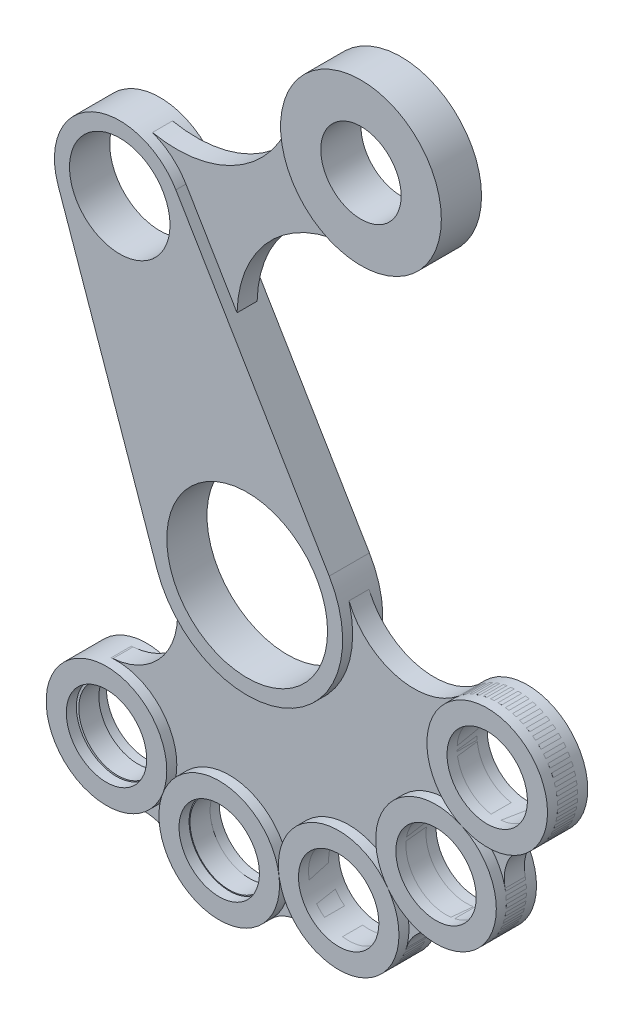
from build123d import *

# Parameters (mm, degrees)
SKETCH1_R             = 25
SKETCH1_R_2           = 40
BOSS_EXTRUDE1_DEPTH   = 10
SKETCH2_R             = 40
SKETCH2_R_2           = 20
BOSS_EXTRUDE2_DEPTH   = 10
SKETCH2_R_3           = 30
BOSS_EXTRUDE2_2_DEPTH = 10
BOSS_EXTRUDE2_3_DEPTH = 10
BOSS_EXTRUDE2_4_DEPTH = 10
BOSS_EXTRUDE2_5_DEPTH = 10
BOSS_EXTRUDE2_6_DEPTH = 10
SKETCH3_R             = 19.3844034
SKETCH3_R_2           = 19.543211722
SKETCH3_R_3           = 20
BOSS_EXTRUDE3_DEPTH   = 5


with BuildPart() as part:
    # Sketch1 → Boss-Extrude1 (new body, symmetric)
    with BuildSketch(Plane.XY):
        with BuildLine():
            Line((-94.071143909, 125.230046249), (-44.841671867, -15.667624713))
            ThreePointArc((-44.841671867, -15.667624713), (20.073190162, -43.050168835), (40.827095802, 24.277525582))
            Line((40.827095802, 24.277525582), (-35.455671293, 152.560938556))
            ThreePointArc((-35.455671293, 152.560938556), (-77.124288005, 165.405378677), (-94.071143909, 125.230046249))
        make_face()
        with Locations((-63.39, 135.95)):
            Circle(SKETCH1_R, mode=Mode.SUBTRACT)
        Circle(SKETCH1_R_2, mode=Mode.SUBTRACT)
    extrude(amount=BOSS_EXTRUDE1_DEPTH, both=True)



with BuildPart() as body_2:
    # Sketch2 → Boss-Extrude2 (new body, symmetric)
    with BuildSketch(Plane.XY):
        with Locations((56.61, 205.95)):
            Circle(SKETCH2_R)
        with Locations((56.61, 205.95)):
            Circle(SKETCH2_R_2, mode=Mode.SUBTRACT)
    extrude(amount=BOSS_EXTRUDE2_DEPTH, both=True)


with BuildPart() as body_3:
    # Sketch2 → Boss-Extrude2 2 (new body, symmetric)
    with BuildSketch(Plane.XY):
        with Locations((119.436136102, -23.248858997)):
            Circle(SKETCH2_R_3)
        with Locations((119.436136102, -23.248858997)):
            Circle(SKETCH2_R_2, mode=Mode.SUBTRACT)
    extrude(amount=BOSS_EXTRUDE2_2_DEPTH, both=True)


with BuildPart() as body_4:
    # Sketch2 → Boss-Extrude2 3 (new body, symmetric)
    with BuildSketch(Plane.XY):
        with Locations((93.96134696, -77.572289653)):
            Circle(SKETCH2_R_3)
        with Locations((93.96134696, -77.572289653)):
            Circle(SKETCH2_R_2, mode=Mode.SUBTRACT)
    extrude(amount=BOSS_EXTRUDE2_3_DEPTH, both=True)


with BuildPart() as body_5:
    # Sketch2 → Boss-Extrude2 4 (new body, symmetric)
    with BuildSketch(Plane.XY):
        with Locations((45.527914191, -112.987012442)):
            Circle(SKETCH2_R_3)
        with Locations((45.527914191, -112.987012442)):
            Circle(SKETCH2_R_2, mode=Mode.SUBTRACT)
    extrude(amount=BOSS_EXTRUDE2_4_DEPTH, both=True)


with BuildPart() as body_6:
    # Sketch2 → Boss-Extrude2 5 (new body, symmetric)
    with BuildSketch(Plane.XY):
        with Locations((-13.897344029, -121.27185918)):
            Circle(SKETCH2_R_3)
        with Locations((-13.897344029, -121.27185918)):
            Circle(SKETCH2_R_2, mode=Mode.SUBTRACT)
    extrude(amount=BOSS_EXTRUDE2_5_DEPTH, both=True)


with BuildPart() as body_7:
    # Sketch2 → Boss-Extrude2 6 (new body, symmetric)
    with BuildSketch(Plane.XY):
        with Locations((-70, -100)):
            Circle(SKETCH2_R_3)
        with Locations((-70, -100)):
            Circle(SKETCH2_R_2, mode=Mode.SUBTRACT)
    extrude(amount=BOSS_EXTRUDE2_6_DEPTH, both=True)


with BuildPart() as part_1:
    add(part.part)

    add(body_2.part)  # Boss-Extrude3 merges body 2
    # Sketch3 → Boss-Extrude3 (add, symmetric)
    with BuildSketch(Plane.XY):
        with BuildLine():
            Line((-35.455671293, 152.560938556), (-10.035224998, 109.811812714))
            ThreePointArc((-10.035224998, 109.811812714), (7.949605082, 150.52428347), (49.454864541, 166.595152312))
            ThreePointArc((49.454864541, 166.595152312), (25.900022644, 180.319992376), (16.61, 205.95))
            ThreePointArc((16.61, 205.95), (-10.311432558, 173.218996741), (-52.146467894, 166.443162935))
            ThreePointArc((-52.146467894, 166.443162935), (-42.607670177, 160.936891906), (-35.455671293, 152.560938556))
        make_face()
        with BuildLine():
            ThreePointArc((100.317104635, -0.130411044), (69.52759131, -7.115068147), (45.641469433, 13.530336844))
            ThreePointArc((45.641469433, 13.530336844), (17.950677407, -42.218066937), (-41.517383039, -23.827464064))
            ThreePointArc((-41.517383039, -23.827464064), (-45.355797063, -54.34871747), (-71.807905384, -70.051147126))
            ThreePointArc((-71.807905384, -70.051147126), (-98.898686089, -104.97930919), (-61.677946881, -128.822620142))
            ThreePointArc((-61.677946881, -128.822620142), (-49.039291741, -129.336814914), (-39.236884492, -137.331363814))
            ThreePointArc((-39.236884492, -137.331363814), (-17.248670052, -151.084081738), (7.244172132, -142.556508447))
            ThreePointArc((7.244172132, -142.556508447), (18.576900661, -136.937855218), (31.01427542, -139.242569752))
            ThreePointArc((31.01427542, -139.242569752), (56.793105611, -140.791606708), (74.223833138, -121.735968713))
            ThreePointArc((74.223833138, -121.735968713), (81.549538172, -111.424128637), (93.597206245, -107.570079597))
            ThreePointArc((93.597206245, -107.570079597), (117.118467222, -96.644462607), (123.333155965, -71.465176113))
            ThreePointArc((123.333155965, -71.465176113), (124.80655175, -58.902170706), (133.523071621, -49.735803851))
            ThreePointArc((133.523071621, -49.735803851), (144.36612299, -6.560666953), (100.317104635, -0.130411044))
        make_face()
        with Locations((-69.393639231, -99.893765389)):
            Circle(SKETCH3_R, mode=Mode.SUBTRACT)
        with Locations((-13.897344029, -121.27185918)):
            Circle(SKETCH3_R_2, mode=Mode.SUBTRACT)
        with Locations((45.527914191, -112.987012442)):
            Circle(SKETCH3_R_3, mode=Mode.SUBTRACT)
        with Locations((93.96134696, -77.572289653)):
            Circle(SKETCH3_R_3, mode=Mode.SUBTRACT)
        with Locations((119.436136102, -23.248858997)):
            Circle(SKETCH3_R_3, mode=Mode.SUBTRACT)
    extrude(amount=BOSS_EXTRUDE3_DEPTH, both=True)


solid = Compound([body_3.part, body_4.part, body_5.part, body_6.part, body_7.part, part_1.part])
